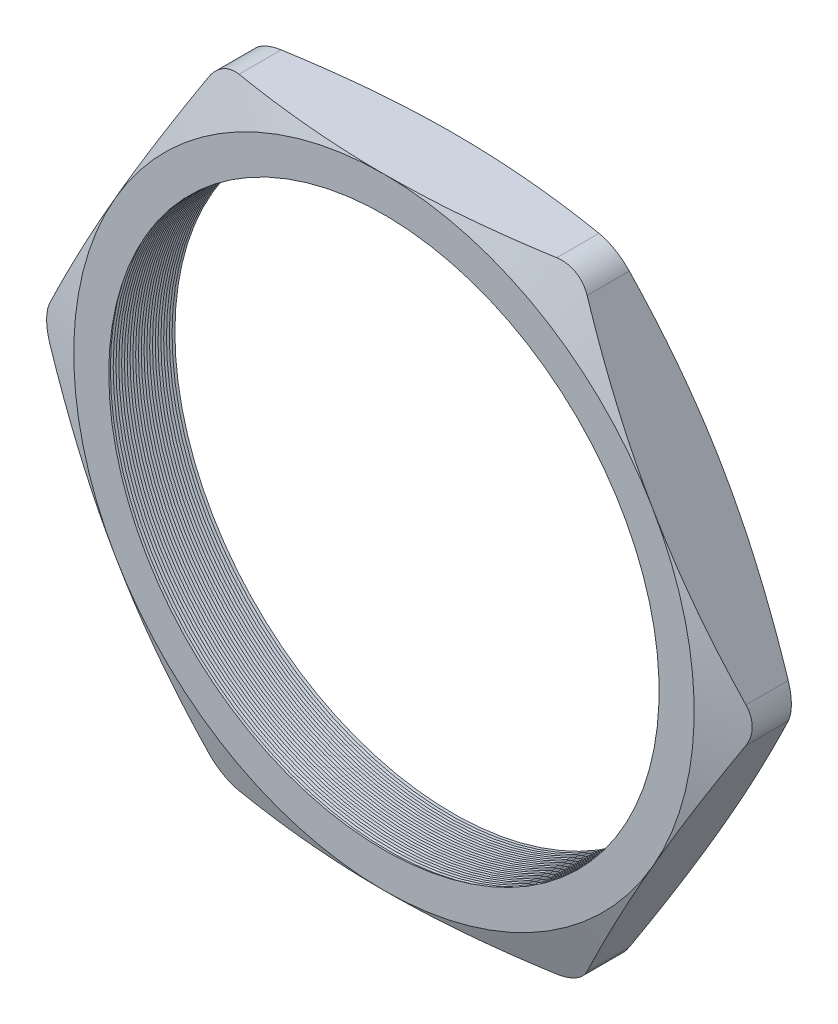
from build123d import *

# Parameters (mm, degrees)
SKETCH1_R          = 19.939
EXTRUDE1_DEPTH     = 5.08
FILLET1_R          = 2.54
SKETCH2_OUTSIDE_W  = 100.192
SKETCH2_OUTSIDE_H  = 94.022
SKETCH2_OUTSIDE_R  = 22.479
CUT_EXTRUDE1_DEPTH = 6.08
CUT_EXTRUDE1_DRAFT = -70
SKETCH3_OUTSIDE_W  = 100.192
SKETCH3_OUTSIDE_H  = 94.022
SKETCH3_OUTSIDE_R  = 22.479
CUT_EXTRUDE2_DEPTH = 6.0800001
CUT_EXTRUDE2_DRAFT = -70
LPATTERN1_COUNT    = 25
LPATTERN1_PITCH    = 0.2032


with BuildPart() as part:
    # Sketch1 → Extrude1 (new body)
    with BuildSketch(Plane.XY):
        Polygon((-25.956513402, 0), (-12.978256701, -22.479), (12.978256701, -22.479), (25.956513402, 0), (12.978256701, 22.479), (-12.978256701, 22.479), align=None)
        Circle(SKETCH1_R, mode=Mode.SUBTRACT)
    extrude(amount=EXTRUDE1_DEPTH)

    # Fillet1
    fillet1_edges = [part.edges().sort_by_distance(p)[0] for p in [
        (25.956513402, 0, 2.54),
        (12.978256701, -22.479, 2.54),
        (-12.978256701, -22.479, 2.54),
        (-25.956513402, 0, 2.54),
        (-12.978256701, 22.479, 2.54),
        (12.978256701, 22.479, 2.54),
    ]]
    fillet(fillet1_edges, radius=FILLET1_R)


with BuildPart() as cut_extrude1_tool:
    # Sketch2 outside → Cut-Extrude1 (with draft: the straight prism first)
    with BuildSketch(Plane.XY.offset(5.08)):
        Rectangle(SKETCH2_OUTSIDE_W, SKETCH2_OUTSIDE_H)
        Circle(SKETCH2_OUTSIDE_R, mode=Mode.SUBTRACT)
    extrude(amount=-CUT_EXTRUDE1_DEPTH)
    # Cut-Extrude1: the draft: its side faces are tilted about the plane it starts from
    cut_extrude1_sides = [cut_extrude1_tool.faces().sort_by_distance(p)[0] for p in [
        (0, -47.011, 2.04),
        (50.096, 0, 2.04),
        (0, 47.011, 2.04),
        (-50.096, 0, 2.04),
        (-22.479, 0, 2.04),
    ]]
    draft(cut_extrude1_sides, Plane.XY.offset(5.08), CUT_EXTRUDE1_DRAFT)


with BuildPart() as part_1:
    add(part.part)

    # Cut-Extrude1: cut by cut_extrude1_tool
    add(cut_extrude1_tool.part, mode=Mode.SUBTRACT)


with BuildPart() as cut_extrude2_tool:
    # Sketch3 outside → Cut-Extrude2 (with draft: the straight prism first)
    with BuildSketch(Plane(origin=(0, 0, 0), x_dir=(-1, 0, 0), z_dir=(0, 0, -1))):
        Rectangle(SKETCH3_OUTSIDE_W, SKETCH3_OUTSIDE_H)
        Circle(SKETCH3_OUTSIDE_R, mode=Mode.SUBTRACT)
    extrude(amount=-CUT_EXTRUDE2_DEPTH)
    # Cut-Extrude2: the draft: its side faces are tilted about the plane it starts from
    cut_extrude2_sides = [cut_extrude2_tool.faces().sort_by_distance(p)[0] for p in [
        (0, -47.011, 3.04000005),
        (-50.096, 0, 3.04000005),
        (0, 47.011, 3.04000005),
        (50.096, 0, 3.04000005),
        (22.479, 0, 3.04000005),
    ]]
    draft(cut_extrude2_sides, Plane(origin=(0, 0, 0), x_dir=(-1, 0, 0), z_dir=(0, 0, -1)), CUT_EXTRUDE2_DRAFT)


with BuildPart() as part_2:
    add(part_1.part)

    # Cut-Extrude2: cut by cut_extrude2_tool
    add(cut_extrude2_tool.part, mode=Mode.SUBTRACT)

    # Sketch4 → Cut-Revolve1 (revolve, cut)
    with BuildSketch(Plane(origin=(0, 0, 0), x_dir=(1, 0, 0), z_dir=(0, 1, 0))):
        Polygon((-19.939, -5.08), (-19.939, -4.640059095), (-20.32, -4.860029547), align=None)
    cut_revolve1 = revolve(axis=Axis((0, 0, 5.08), (0, 0, -1)), mode=Mode.SUBTRACT)

    # LPattern1: Cut-Revolve1 ×25
    with Locations(*[(0, 0, -i * LPATTERN1_PITCH) for i in range(1, LPATTERN1_COUNT)]):
        add(cut_revolve1, mode=Mode.SUBTRACT)


solid = part_2.part
